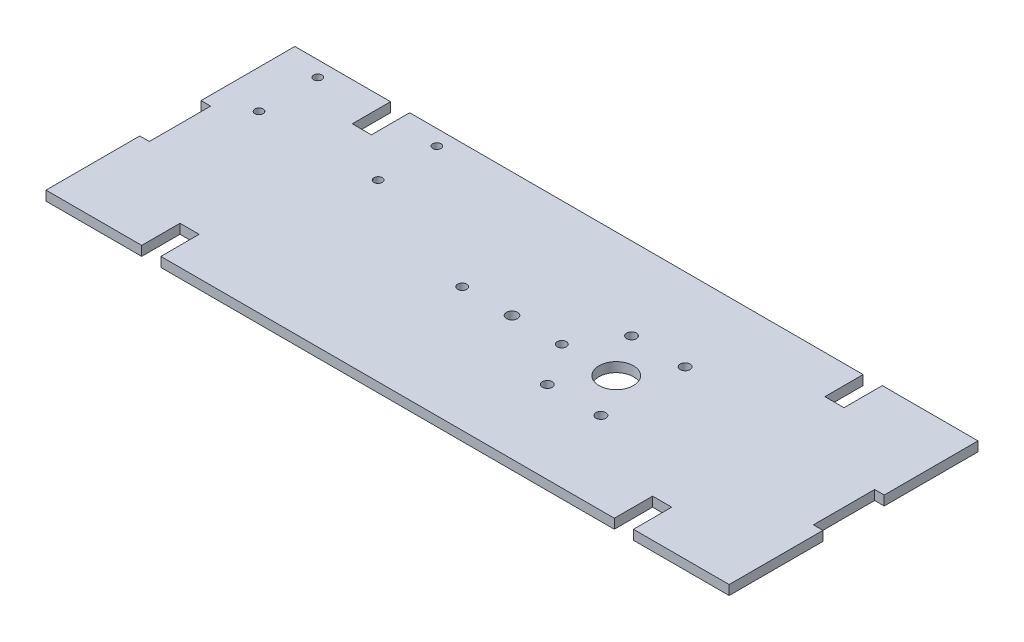
from build123d import *

# Parameters (mm, degrees)
SKETCH1_R           = 1.8288
BOSS_EXTRUDE1_DEPTH = 3.175
SKETCH2_R           = 1.63195
SKETCH2_R_2         = 5.715
SKETCH2_R_3         = 1.524
CUT_EXTRUDE1_DEPTH  = 4.175
SKETCH3_R           = 1.375
CUT_EXTRUDE2_DEPTH  = 4.175


with BuildPart() as part:
    # Sketch1 → Boss-Extrude1 (new body)
    with BuildSketch(Plane(origin=(0, 0, 0), x_dir=(1, 0, 0), z_dir=(0, 1, 0))):
        Polygon((-226.6315, 82.55), (-194.8815, 82.55), (-194.8815, 69.85), (-188.5315, 69.85), (-188.5315, 82.55), (-38.1, 82.55), (-38.1, 69.85), (-31.75, 69.85), (-31.75, 82.55), (0, 82.55), (0, 51.435), (-3.175, 51.435), (-3.175, 31.115), (0, 31.115), (0, 0), (-31.75, 0), (-31.75, 12.7), (-38.1, 12.7), (-38.1, 0), (-188.5315, 0), (-188.5315, 12.7), (-194.8815, 12.7), (-194.8815, 0), (-226.6315, 0), (-226.6315, 31.115), (-223.4565, 31.115), (-223.4565, 51.435), (-226.6315, 51.435), align=None)
        with Locations((-113.31575, 41.275)):
            Circle(SKETCH1_R, mode=Mode.SUBTRACT)
    extrude(amount=BOSS_EXTRUDE1_DEPTH)

    # Sketch2 → Cut-Extrude1 (cut, through all)
    with BuildSketch(Plane(origin=(0, 3.175, 0), x_dir=(1, 0, 0), z_dir=(0, 1, 0))):
        with Locations((-87.63, 27.305)):
            Circle(SKETCH2_R)
        with Locations((-69.85, 27.305)):
            Circle(SKETCH2_R)
        with Locations((-69.85, 55.245)):
            Circle(SKETCH2_R)
        with Locations((-87.63, 55.245)):
            Circle(SKETCH2_R)
        with Locations((-78.74, 41.275)):
            Circle(SKETCH2_R_2)
        with Locations((-129.82575, 41.275)):
            Circle(SKETCH2_R_3)
        with Locations((-96.80575, 41.275)):
            Circle(SKETCH2_R_3)
    extrude(amount=-CUT_EXTRUDE1_DEPTH, mode=Mode.SUBTRACT)

    # Sketch3 → Cut-Extrude2 (cut, through all)
    with BuildSketch(Plane(origin=(0, 3.175, 0), x_dir=(1, 0, 0), z_dir=(0, 1, 0))):
        with Locations((-174.4315, 57.97)):
            Circle(SKETCH3_R)
        with Locations((-213.9315, 57.97)):
            Circle(SKETCH3_R)
        with Locations((-213.9315, 77.47)):
            Circle(SKETCH3_R)
        with Locations((-174.4315, 77.47)):
            Circle(SKETCH3_R)
    extrude(amount=-CUT_EXTRUDE2_DEPTH, mode=Mode.SUBTRACT)


solid = part.part
